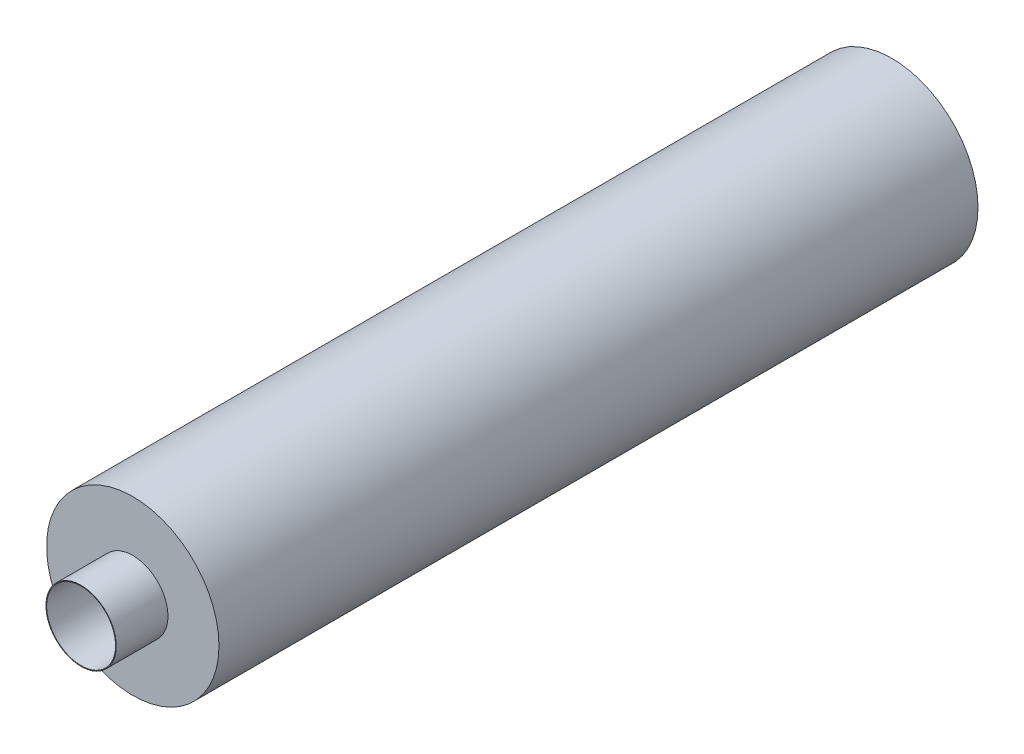
from build123d import *

# Parameters (mm, degrees)
SKETCH1_R           = 250
BOSS_EXTRUDE1_DEPTH = 2200
SHELL1_T            = -2
SKETCH10_R          = 250
SKETCH10_R_2        = 100
BOSS_EXTRUDE4_DEPTH = 2
SKETCH11_R          = 102
SKETCH11_R_2        = 100
EXTRUDE_THIN2_DEPTH = 150


with BuildPart() as part:
    # Sketch1 → Boss-Extrude1 (new body)
    with BuildSketch(Plane.XY):
        Circle(SKETCH1_R)
    extrude(amount=BOSS_EXTRUDE1_DEPTH)

    # Shell1
    shell1_openings = [part.faces().sort_by_distance(p)[0] for p in [
        (0, 0, 2200),
    ]]
    offset(amount=SHELL1_T, openings=shell1_openings, kind=Kind.INTERSECTION)

    # Sketch10 → Boss-Extrude4 (add)
    with BuildSketch(Plane.XY.offset(2200)):
        Circle(SKETCH10_R)
        Circle(SKETCH10_R_2, mode=Mode.SUBTRACT)
    extrude(amount=BOSS_EXTRUDE4_DEPTH)

    # Sketch11 → Extrude-Thin2 (add)
    with BuildSketch(Plane.XY.offset(2202)):
        Circle(SKETCH11_R)
        Circle(SKETCH11_R_2, mode=Mode.SUBTRACT)
    extrude(amount=EXTRUDE_THIN2_DEPTH)


solid = part.part
